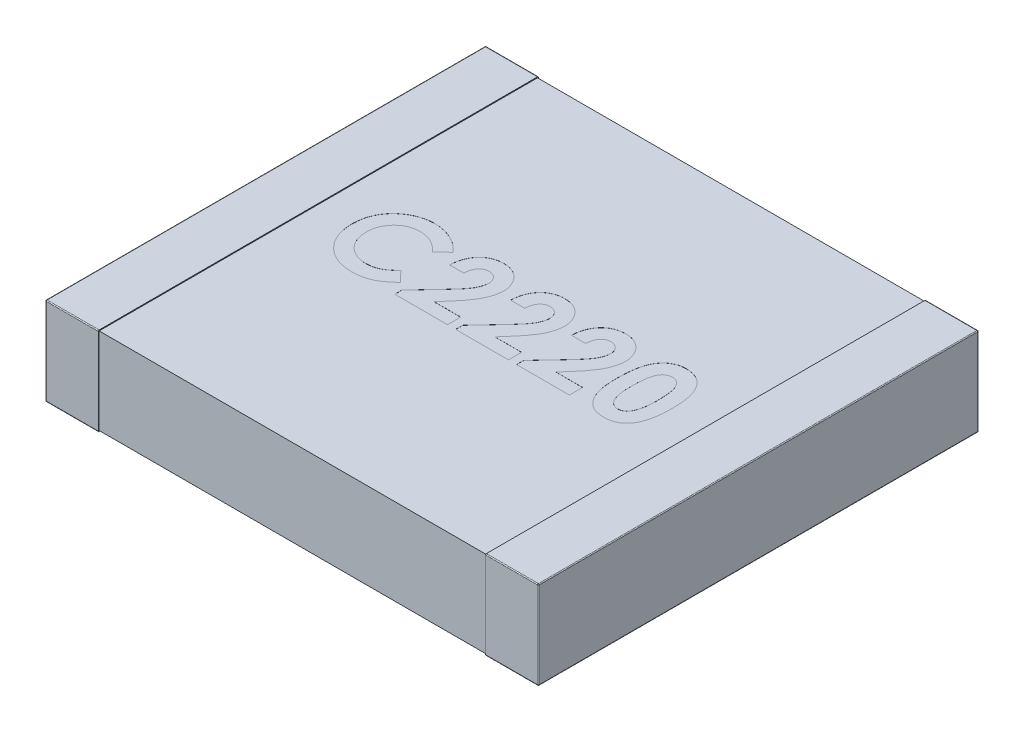
from build123d import *

# Parameters (mm, degrees)
SKETCH1_W            = 0.6
SKETCH1_H            = 5
THICKNESS_DEPTH      = 1
FILLET1_R            = 0.01
SKETCH2_W            = 4.98
SKETCH2_H            = 0.98
BOSS_EXTRUDE2_DEPTH  = 2.2
FILLET1_OF_MIRROR3_R = 0.01
CUT_EXTRUDE1_DEPTH   = 0.001


with BuildPart() as part:
    # Sketch1 → THICKNESS (new body)
    with BuildSketch(Plane(origin=(0, 0, 0), x_dir=(1, 0, 0), z_dir=(0, 1, 0))):
        with Locations((-2.5, 0)):
            Rectangle(SKETCH1_W, SKETCH1_H)
    thickness = extrude(amount=THICKNESS_DEPTH)

    # Fillet1
    fillet1_edges = [part.edges().sort_by_distance(p)[0] for p in [
        (-2.5, 1, -2.5),
        (-2.8, 1, 0),
        (-2.5, 0, -2.5),
        (-2.5, 0, 2.5),
        (-2.8, 0, 0),
        (-2.5, 1, 2.5),
        (-2.8, 0.5, -2.5),
        (-2.8, 0.5, 2.5),
    ]]
    fillet(fillet1_edges, radius=FILLET1_R)

    # Sketch2 → Boss-Extrude2 (add)
    with BuildSketch(Plane(origin=(0, 0, 0), x_dir=(0, 0, -1), z_dir=(1, 0, 0))):
        with Locations((0, 0.5)):
            Rectangle(SKETCH2_W, SKETCH2_H)
    boss_extrude2 = extrude(amount=-BOSS_EXTRUDE2_DEPTH)

    # Mirror3: THICKNESS, Boss-Extrude2 across plane
    add(thickness.mirror(Plane(origin=(0, 0, 0), x_dir=(0, 0, 1), z_dir=(1, 0, 0))))
    add(boss_extrude2.mirror(Plane(origin=(0, 0, 0), x_dir=(0, 0, 1), z_dir=(1, 0, 0))))

    # Fillet1 of Mirror3
    fillet1_of_mirror3_edges = [part.edges().sort_by_distance(p)[0] for p in [
        (2.5, 1, -2.5),
        (2.8, 1, 0),
        (2.5, 0, -2.5),
        (2.5, 0, 2.5),
        (2.8, 0, 0),
        (2.5, 1, 2.5),
        (2.8, 0.5, -2.5),
        (2.8, 0.5, 2.5),
    ]]
    fillet(fillet1_of_mirror3_edges, radius=FILLET1_OF_MIRROR3_R)

    # Sketch3 → Cut-Extrude1 (cut)
    with BuildSketch(Plane(origin=(0, 0.99, 0), x_dir=(1, 0, 0), z_dir=(0, 1, 0))):
        with BuildLine():
            Line((-0.963461538, 0.293870192), (-1.081911058, 0.180649038))
            add(Edge.make_bspline(
                [(-1.081911058, 0.180649038), (-1.091958911, 0.191038536), (-1.111585516, 0.211332478), (-1.143211363, 0.23819987), (-1.176101092, 0.260590206), (-1.2096149, 0.279447204), (-1.244355602, 0.293713867), (-1.279921502, 0.304110224), (-1.316539698, 0.310448491), (-1.341321485, 0.3111737), (-1.353786058, 0.311538462)],
                knots=[0, 0, 0, 0, 4.3344e-05, 8.4665e-05, 0.000124221, 0.000162552, 0.000199817, 0.000236617, 0.000273548, 0.00031092, 0.00031092, 0.00031092, 0.00031092], degree=3))
            add(Edge.make_bspline(
                [(-1.353786058, 0.311538462), (-1.364195491, 0.311250288), (-1.384737361, 0.310681608), (-1.414898208, 0.306512625), (-1.443748618, 0.299423089), (-1.471387348, 0.289652395), (-1.497733072, 0.277009635), (-1.522841027, 0.261504594), (-1.546649309, 0.243277306), (-1.568843425, 0.222422079), (-1.589145823, 0.199636176), (-1.607084284, 0.175323672), (-1.622110622, 0.149540266), (-1.634442494, 0.122547072), (-1.644048545, 0.094219153), (-1.650908473, 0.064575581), (-1.654876071, 0.033581052), (-1.655468262, 0.012511202), (-1.655769231, 0.001802885)],
                knots=[0, 0, 0, 0, 3.1223e-05, 6.1616e-05, 9.1131e-05, 0.000120213, 0.000149404, 0.000178625, 0.00020859, 0.000239203, 0.000269851, 0.000300033, 0.000329687, 0.000359215, 0.000388919, 0.000419269, 0.000450353, 0.000482477, 0.000482477, 0.000482477, 0.000482477], degree=3))
            add(Edge.make_bspline(
                [(-1.655769231, 0.001802885), (-1.655682495, -0.005712962), (-1.655511537, -0.02052685), (-1.6536401, -0.042440701), (-1.650626645, -0.063702318), (-1.646265428, -0.084279494), (-1.640811685, -0.104190062), (-1.634413201, -0.123605789), (-1.626386398, -0.142258394), (-1.617476526, -0.160364514), (-1.607114447, -0.177430102), (-1.595942214, -0.193703557), (-1.583827751, -0.209105106), (-1.570692593, -0.22357179), (-1.556351878, -0.236877525), (-1.541176261, -0.249422432), (-1.52490975, -0.260892467), (-1.507890241, -0.271575486), (-1.489970709, -0.280855915), (-1.47163735, -0.289262191), (-1.452612195, -0.296089337), (-1.433126886, -0.30159264), (-1.413251056, -0.306272376), (-1.392790303, -0.309153834), (-1.371921994, -0.311335928), (-1.35781852, -0.31147066), (-1.350721154, -0.311538462)],
                knots=[0, 0, 0, 0, 2.2543e-05, 4.4432e-05, 6.5926e-05, 8.6929e-05, 0.000107485, 0.000127838, 0.000148197, 0.000168354, 0.000188328, 0.000208032, 0.000227544, 0.00024707, 0.000266585, 0.000286184, 0.000306094, 0.000326255, 0.000346416, 0.000366589, 0.000386721, 0.000406979, 0.000427316, 0.000447918, 0.000468925, 0.000490206, 0.000490206, 0.000490206, 0.000490206], degree=3))
            add(Edge.make_bspline(
                [(-1.350721154, -0.311538462), (-1.338682801, -0.311190248), (-1.315030568, -0.3105061), (-1.280317515, -0.305156159), (-1.247239434, -0.296355809), (-1.220810205, -0.285963106), (-1.200103603, -0.275700177), (-1.184339972, -0.266207473), (-1.16803915, -0.255588842), (-1.151471878, -0.243443524), (-1.134451808, -0.229917269), (-1.117279384, -0.214713826), (-1.099514987, -0.198333822), (-1.087877707, -0.186643092), (-1.081911058, -0.180649038)],
                knots=[0, 0, 0, 0, 3.6103e-05, 7.0932e-05, 0.000105088, 0.0001386, 0.000155935, 0.000174363, 0.000193765, 0.000214284, 0.000235964, 0.000258962, 0.000283073, 0.000308443, 0.000308443, 0.000308443, 0.000308443], degree=3))
            Line((-1.081911058, -0.180649038), (-0.967067308, -0.301262019))
            add(Edge.make_bspline(
                [(-0.967067308, -0.301262019), (-0.975140205, -0.309056148), (-0.990896775, -0.324268621), (-1.014665122, -0.345868914), (-1.038403556, -0.365279177), (-1.061538606, -0.38320392), (-1.084449247, -0.399120951), (-1.107133051, -0.413046166), (-1.129333226, -0.425331754), (-1.151510766, -0.435770525), (-1.173803671, -0.444634125), (-1.196740451, -0.452265103), (-1.220391226, -0.458720636), (-1.244900443, -0.463929404), (-1.270039495, -0.468106132), (-1.296043651, -0.470925399), (-1.322748032, -0.472820699), (-1.340862027, -0.472991008), (-1.35, -0.473076923)],
                knots=[0, 0, 0, 0, 3.3664e-05, 6.5705e-05, 9.6315e-05, 0.000125631, 0.000153488, 0.000179956, 0.000205453, 0.000229567, 0.000253437, 0.000277383, 0.00030205, 0.000326944, 0.000352523, 0.000378465, 0.000405388, 0.000432797, 0.000432797, 0.000432797, 0.000432797], degree=3))
            add(Edge.make_bspline(
                [(-1.35, -0.473076923), (-1.366785325, -0.472649032), (-1.39962954, -0.471811767), (-1.447761881, -0.465608204), (-1.493486313, -0.455208039), (-1.536914075, -0.440499337), (-1.578031358, -0.42170966), (-1.616827643, -0.398674399), (-1.653240398, -0.371454753), (-1.686975481, -0.340369765), (-1.717490469, -0.306039005), (-1.744462185, -0.269177187), (-1.766773189, -0.229603149), (-1.785298496, -0.187901525), (-1.799785043, -0.143882016), (-1.809981116, -0.097497005), (-1.81626896, -0.048791279), (-1.816956859, -0.015524146), (-1.817307692, 0.001442308)],
                knots=[0, 0, 0, 0, 5.0347e-05, 9.8515e-05, 0.000145311, 0.000190808, 0.000235824, 0.000280688, 0.000325905, 0.000371966, 0.000418065, 0.000463503, 0.000508719, 0.000554081, 0.000600204, 0.000647488, 0.000696371, 0.000747251, 0.000747251, 0.000747251, 0.000747251], degree=3))
            add(Edge.make_bspline(
                [(-1.817307692, 0.001442308), (-1.817159447, 0.012507684), (-1.816865662, 0.034436556), (-1.81377795, 0.06673956), (-1.809473501, 0.098229211), (-1.802644883, 0.128578542), (-1.794413658, 0.158196414), (-1.784177048, 0.186760916), (-1.771951402, 0.214354145), (-1.758130783, 0.241022293), (-1.742495654, 0.266590656), (-1.725029498, 0.290839561), (-1.706181964, 0.313956205), (-1.685500174, 0.335633904), (-1.663284662, 0.35606299), (-1.639435128, 0.375132756), (-1.614095016, 0.393116684), (-1.587195738, 0.40955101), (-1.559259876, 0.424416732), (-1.530639775, 0.437528934), (-1.50140575, 0.448487715), (-1.471681407, 0.45757762), (-1.44134116, 0.464362591), (-1.41060157, 0.469498595), (-1.37920108, 0.472369654), (-1.358118371, 0.472839665), (-1.347475962, 0.473076923)],
                knots=[0, 0, 0, 0, 3.3185e-05, 6.5765e-05, 9.7279e-05, 0.00012847, 0.000159004, 0.000189457, 0.000219405, 0.000249482, 0.000279506, 0.000309225, 0.000339073, 0.000368914, 0.000399027, 0.000429548, 0.000460462, 0.000492186, 0.000524045, 0.000555348, 0.000586557, 0.00061764, 0.000648518, 0.000679758, 0.000711081, 0.00074301, 0.00074301, 0.00074301, 0.00074301], degree=3))
            add(Edge.make_bspline(
                [(-1.347475962, 0.473076923), (-1.338396895, 0.472940921), (-1.320333158, 0.47267033), (-1.293433223, 0.470414663), (-1.266748421, 0.466872159), (-1.240374292, 0.461527277), (-1.21412218, 0.455182225), (-1.18833707, 0.446874256), (-1.162612185, 0.437613459), (-1.137350983, 0.426544066), (-1.112518204, 0.414460824), (-1.088695593, 0.400751948), (-1.065483171, 0.386261065), (-1.043395312, 0.370130543), (-1.022018263, 0.352945465), (-1.001463806, 0.334625653), (-0.981912319, 0.314865662), (-0.969642891, 0.300904063), (-0.963461538, 0.293870192)],
                knots=[0, 0, 0, 0, 2.7233e-05, 5.4183e-05, 8.093e-05, 0.000107943, 0.000134878, 0.000161906, 0.000189169, 0.000216867, 0.000244603, 0.000271975, 0.000299284, 0.000326656, 0.000353968, 0.000381546, 0.000409211, 0.000437299, 0.000437299, 0.000437299, 0.000437299], degree=3))
        make_face()
        with BuildLine():
            Line((-0.698076923, 0.15), (-0.859615385, 0.15))
            add(Edge.make_bspline(
                [(-0.859615385, 0.15), (-0.858917725, 0.16221953), (-0.857554539, 0.186095758), (-0.852132132, 0.220776744), (-0.844866293, 0.253546461), (-0.835169065, 0.284290279), (-0.822983865, 0.312997026), (-0.808624247, 0.339764564), (-0.791723358, 0.364451962), (-0.772640902, 0.386940164), (-0.751700849, 0.407114537), (-0.729337933, 0.425002403), (-0.705210084, 0.439763021), (-0.679758138, 0.451909642), (-0.652986428, 0.461614228), (-0.624641652, 0.46810253), (-0.594969234, 0.472496471), (-0.574656062, 0.472880958), (-0.564302885, 0.473076923)],
                knots=[0, 0, 0, 0, 3.6698e-05, 7.1706e-05, 0.000105165, 0.000137323, 0.000168264, 0.000198596, 0.0002283, 0.000257848, 0.000286918, 0.000315413, 0.000343582, 0.000371564, 0.000399906, 0.000428812, 0.000458668, 0.000489703, 0.000489703, 0.000489703, 0.000489703], degree=3))
            add(Edge.make_bspline(
                [(-0.564302885, 0.473076923), (-0.551594507, 0.472680388), (-0.526784775, 0.471906259), (-0.490734267, 0.465302682), (-0.457067034, 0.454257178), (-0.425807549, 0.438823696), (-0.39722193, 0.419217074), (-0.371314916, 0.395839388), (-0.348869978, 0.368200159), (-0.329744807, 0.337449412), (-0.313854077, 0.304888698), (-0.302718514, 0.27121957), (-0.295399229, 0.237335469), (-0.294618582, 0.214519631), (-0.294230769, 0.203185096)],
                knots=[0, 0, 0, 0, 3.8102e-05, 7.4385e-05, 0.000109504, 0.000144094, 0.000178598, 0.000213186, 0.000248412, 0.000285028, 0.000321638, 0.000356814, 0.000391217, 0.00042518, 0.00042518, 0.00042518, 0.00042518], degree=3))
            add(Edge.make_bspline(
                [(-0.294230769, 0.203185096), (-0.294381763, 0.196329168), (-0.294685676, 0.182529879), (-0.296798825, 0.161648167), (-0.299968966, 0.140377702), (-0.304748765, 0.118736722), (-0.310709567, 0.09671916), (-0.317940882, 0.074259124), (-0.326610446, 0.051483956), (-0.336573583, 0.028137325), (-0.34845963, 0.004143433), (-0.36229928, -0.020857397), (-0.378459868, -0.046842989), (-0.396746195, -0.073960064), (-0.417247073, -0.102165855), (-0.44006258, -0.131375398), (-0.464929936, -0.161691618), (-0.482578998, -0.181956309), (-0.491646635, -0.192367788)],
                knots=[0, 0, 0, 0, 2.0566e-05, 4.1393e-05, 6.2913e-05, 8.505e-05, 0.000107836, 0.000131326, 0.000155803, 0.00018092, 0.000207447, 0.000236096, 0.000266616, 0.000299218, 0.000334198, 0.000371199, 0.000410396, 0.000451813, 0.000451813, 0.000451813, 0.000451813], degree=3))
            Line((-0.491646635, -0.192367788), (-0.585576923, -0.3))
            Line((-0.585576923, -0.3), (-0.282692308, -0.3))
            Line((-0.282692308, -0.3), (-0.282692308, -0.45))
            Line((-0.282692308, -0.45), (-0.882692308, -0.45))
            Line((-0.882692308, -0.45), (-0.882692308, -0.368149038))
            Line((-0.882692308, -0.368149038), (-0.616225962, -0.084555288))
            add(Edge.make_bspline(
                [(-0.616225962, -0.084555288), (-0.608511076, -0.076282771), (-0.593569631, -0.060261357), (-0.572309494, -0.036732207), (-0.553070948, -0.014403605), (-0.53625292, 0.006962204), (-0.520972822, 0.026672198), (-0.507911991, 0.045320463), (-0.496950932, 0.062738412), (-0.485051148, 0.083741415), (-0.473750264, 0.108791234), (-0.46338102, 0.137649653), (-0.457060248, 0.165231655), (-0.456187781, 0.18320468), (-0.455769231, 0.191826923)],
                knots=[0, 0, 0, 0, 3.3934e-05, 6.5721e-05, 9.5132e-05, 0.000122331, 0.000147284, 0.000169941, 0.000190599, 0.000209004, 0.000242322, 0.000272884, 0.000300926, 0.000326784, 0.000326784, 0.000326784, 0.000326784], degree=3))
            add(Edge.make_bspline(
                [(-0.455769231, 0.191826923), (-0.456082171, 0.200168278), (-0.456688542, 0.21633099), (-0.463352074, 0.239322362), (-0.473675448, 0.260138702), (-0.48822254, 0.278157994), (-0.505843624, 0.292965642), (-0.526206442, 0.303979155), (-0.549144978, 0.310333901), (-0.565225328, 0.311129288), (-0.573497596, 0.311538462)],
                knots=[0, 0, 0, 0, 2.4959e-05, 4.8362e-05, 7.1179e-05, 9.4267e-05, 0.000117305, 0.000139809, 0.000163212, 0.000188006, 0.000188006, 0.000188006, 0.000188006], degree=3))
            add(Edge.make_bspline(
                [(-0.573497596, 0.311538462), (-0.577771155, 0.311387308), (-0.586184343, 0.311089738), (-0.598551071, 0.309108893), (-0.610318902, 0.305617861), (-0.621618817, 0.300940369), (-0.632330221, 0.294740321), (-0.642426096, 0.287097773), (-0.652012816, 0.27820694), (-0.661046411, 0.268095624), (-0.669268162, 0.256811392), (-0.676570692, 0.244457302), (-0.682608668, 0.231041024), (-0.687924721, 0.216739672), (-0.692024716, 0.201399639), (-0.695010021, 0.185112732), (-0.697279549, 0.167905449), (-0.697806297, 0.15607706), (-0.698076923, 0.15)],
                knots=[0, 0, 0, 0, 1.2821e-05, 2.524e-05, 3.7449e-05, 4.957e-05, 6.1847e-05, 7.4467e-05, 8.748e-05, 0.000101015, 0.000115079, 0.000129302, 0.000143984, 0.000159156, 0.000175032, 0.000191545, 0.000208808, 0.00022705, 0.00022705, 0.00022705, 0.00022705], degree=3))
        make_face()
        with BuildLine():
            Line((-0.005769231, 0.15), (-0.167307692, 0.15))
            add(Edge.make_bspline(
                [(-0.167307692, 0.15), (-0.166610032, 0.16221953), (-0.165246847, 0.186095758), (-0.15982444, 0.220776744), (-0.1525586, 0.253546461), (-0.142861373, 0.284290279), (-0.130676172, 0.312997026), (-0.116316555, 0.339764564), (-0.099415665, 0.364451962), (-0.08033321, 0.386940164), (-0.059393156, 0.407114537), (-0.03703024, 0.425002403), (-0.012902392, 0.439763021), (0.012549555, 0.451909642), (0.039321265, 0.461614228), (0.067666041, 0.46810253), (0.097338458, 0.472496471), (0.117651631, 0.472880958), (0.128004808, 0.473076923)],
                knots=[0, 0, 0, 0, 3.6698e-05, 7.1706e-05, 0.000105165, 0.000137323, 0.000168264, 0.000198596, 0.0002283, 0.000257848, 0.000286918, 0.000315413, 0.000343582, 0.000371564, 0.000399906, 0.000428812, 0.000458668, 0.000489703, 0.000489703, 0.000489703, 0.000489703], degree=3))
            add(Edge.make_bspline(
                [(0.128004808, 0.473076923), (0.140713186, 0.472680388), (0.165522917, 0.471906259), (0.201573426, 0.465302682), (0.235240659, 0.454257178), (0.266500143, 0.438823696), (0.295085763, 0.419217074), (0.320992776, 0.395839388), (0.343437714, 0.368200159), (0.362562885, 0.337449412), (0.378453616, 0.304888698), (0.389589178, 0.27121957), (0.396908463, 0.237335469), (0.39768911, 0.214519631), (0.398076923, 0.203185096)],
                knots=[0, 0, 0, 0, 3.8102e-05, 7.4385e-05, 0.000109504, 0.000144094, 0.000178598, 0.000213186, 0.000248412, 0.000285028, 0.000321638, 0.000356814, 0.000391217, 0.00042518, 0.00042518, 0.00042518, 0.00042518], degree=3))
            add(Edge.make_bspline(
                [(0.398076923, 0.203185096), (0.397925929, 0.196329168), (0.397622016, 0.182529879), (0.395508867, 0.161648167), (0.392338727, 0.140377702), (0.387558927, 0.118736722), (0.381598125, 0.09671916), (0.374366811, 0.074259124), (0.365697246, 0.051483956), (0.35573411, 0.028137325), (0.343848063, 0.004143433), (0.330008413, -0.020857397), (0.313847824, -0.046842989), (0.295561498, -0.073960064), (0.27506062, -0.102165855), (0.252245112, -0.131375398), (0.227377756, -0.161691618), (0.209728694, -0.181956309), (0.200661058, -0.192367788)],
                knots=[0, 0, 0, 0, 2.0566e-05, 4.1393e-05, 6.2913e-05, 8.505e-05, 0.000107836, 0.000131326, 0.000155803, 0.00018092, 0.000207447, 0.000236096, 0.000266616, 0.000299218, 0.000334198, 0.000371199, 0.000410396, 0.000451813, 0.000451813, 0.000451813, 0.000451813], degree=3))
            Line((0.200661058, -0.192367788), (0.106730769, -0.3))
            Line((0.106730769, -0.3), (0.409615385, -0.3))
            Line((0.409615385, -0.3), (0.409615385, -0.45))
            Line((0.409615385, -0.45), (-0.190384615, -0.45))
            Line((-0.190384615, -0.45), (-0.190384615, -0.368149038))
            Line((-0.190384615, -0.368149038), (0.076081731, -0.084555288))
            add(Edge.make_bspline(
                [(0.076081731, -0.084555288), (0.083796616, -0.076282771), (0.098738062, -0.060261357), (0.119998198, -0.036732207), (0.139236744, -0.014403605), (0.156054772, 0.006962204), (0.171334871, 0.026672198), (0.184395701, 0.045320463), (0.19535676, 0.062738412), (0.207256545, 0.083741415), (0.218557428, 0.108791234), (0.228926673, 0.137649653), (0.235247445, 0.165231655), (0.236119911, 0.18320468), (0.236538462, 0.191826923)],
                knots=[0, 0, 0, 0, 3.3934e-05, 6.5721e-05, 9.5132e-05, 0.000122331, 0.000147284, 0.000169941, 0.000190599, 0.000209004, 0.000242322, 0.000272884, 0.000300926, 0.000326784, 0.000326784, 0.000326784, 0.000326784], degree=3))
            add(Edge.make_bspline(
                [(0.236538462, 0.191826923), (0.236225521, 0.200168278), (0.23561915, 0.21633099), (0.228955619, 0.239322362), (0.218632245, 0.260138702), (0.204085153, 0.278157994), (0.186464068, 0.292965642), (0.16610125, 0.303979155), (0.143162715, 0.310333901), (0.127082365, 0.311129288), (0.118810096, 0.311538462)],
                knots=[0, 0, 0, 0, 2.4959e-05, 4.8362e-05, 7.1179e-05, 9.4267e-05, 0.000117305, 0.000139809, 0.000163212, 0.000188006, 0.000188006, 0.000188006, 0.000188006], degree=3))
            add(Edge.make_bspline(
                [(0.118810096, 0.311538462), (0.114536537, 0.311387308), (0.106123349, 0.311089738), (0.093756621, 0.309108893), (0.081988791, 0.305617861), (0.070688876, 0.300940369), (0.059977472, 0.294740321), (0.049881596, 0.287097773), (0.040294876, 0.27820694), (0.031261281, 0.268095624), (0.02303953, 0.256811392), (0.015737001, 0.244457302), (0.009699025, 0.231041024), (0.004382971, 0.216739672), (0.000282976, 0.201399639), (-0.002702329, 0.185112732), (-0.004971857, 0.167905449), (-0.005498604, 0.15607706), (-0.005769231, 0.15)],
                knots=[0, 0, 0, 0, 1.2821e-05, 2.524e-05, 3.7449e-05, 4.957e-05, 6.1847e-05, 7.4467e-05, 8.748e-05, 0.000101015, 0.000115079, 0.000129302, 0.000143984, 0.000159156, 0.000175032, 0.000191545, 0.000208808, 0.00022705, 0.00022705, 0.00022705, 0.00022705], degree=3))
        make_face()
        with BuildLine():
            Line((0.686538462, 0.15), (0.525, 0.15))
            add(Edge.make_bspline(
                [(0.525, 0.15), (0.52569766, 0.16221953), (0.527060845, 0.186095758), (0.532483252, 0.220776744), (0.539749092, 0.253546461), (0.549446319, 0.284290279), (0.56163152, 0.312997026), (0.575991137, 0.339764564), (0.592892027, 0.364451962), (0.611974482, 0.386940164), (0.632914536, 0.407114537), (0.655277452, 0.425002403), (0.679405301, 0.439763021), (0.704857247, 0.451909642), (0.731628957, 0.461614228), (0.759973733, 0.46810253), (0.78964615, 0.472496471), (0.809959323, 0.472880958), (0.8203125, 0.473076923)],
                knots=[0, 0, 0, 0, 3.6698e-05, 7.1706e-05, 0.000105165, 0.000137323, 0.000168264, 0.000198596, 0.0002283, 0.000257848, 0.000286918, 0.000315413, 0.000343582, 0.000371564, 0.000399906, 0.000428812, 0.000458668, 0.000489703, 0.000489703, 0.000489703, 0.000489703], degree=3))
            add(Edge.make_bspline(
                [(0.8203125, 0.473076923), (0.833020878, 0.472680388), (0.85783061, 0.471906259), (0.893881118, 0.465302682), (0.927548351, 0.454257178), (0.958807836, 0.438823696), (0.987393455, 0.419217074), (1.013300469, 0.395839388), (1.035745407, 0.368200159), (1.054870577, 0.337449412), (1.070761308, 0.304888698), (1.08189687, 0.27121957), (1.089216156, 0.237335469), (1.089996803, 0.214519631), (1.090384615, 0.203185096)],
                knots=[0, 0, 0, 0, 3.8102e-05, 7.4385e-05, 0.000109504, 0.000144094, 0.000178598, 0.000213186, 0.000248412, 0.000285028, 0.000321638, 0.000356814, 0.000391217, 0.00042518, 0.00042518, 0.00042518, 0.00042518], degree=3))
            add(Edge.make_bspline(
                [(1.090384615, 0.203185096), (1.090233622, 0.196329168), (1.089929708, 0.182529879), (1.08781656, 0.161648167), (1.084646419, 0.140377702), (1.079866619, 0.118736722), (1.073905817, 0.09671916), (1.066674503, 0.074259124), (1.058004939, 0.051483956), (1.048041802, 0.028137325), (1.036155755, 0.004143433), (1.022316105, -0.020857397), (1.006155517, -0.046842989), (0.98786919, -0.073960064), (0.967368312, -0.102165855), (0.944552804, -0.131375398), (0.919685448, -0.161691618), (0.902036386, -0.181956309), (0.89296875, -0.192367788)],
                knots=[0, 0, 0, 0, 2.0566e-05, 4.1393e-05, 6.2913e-05, 8.505e-05, 0.000107836, 0.000131326, 0.000155803, 0.00018092, 0.000207447, 0.000236096, 0.000266616, 0.000299218, 0.000334198, 0.000371199, 0.000410396, 0.000451813, 0.000451813, 0.000451813, 0.000451813], degree=3))
            Line((0.89296875, -0.192367788), (0.799038462, -0.3))
            Line((0.799038462, -0.3), (1.101923077, -0.3))
            Line((1.101923077, -0.3), (1.101923077, -0.45))
            Line((1.101923077, -0.45), (0.501923077, -0.45))
            Line((0.501923077, -0.45), (0.501923077, -0.368149038))
            Line((0.501923077, -0.368149038), (0.768389423, -0.084555288))
            add(Edge.make_bspline(
                [(0.768389423, -0.084555288), (0.776104309, -0.076282771), (0.791045754, -0.060261357), (0.812305891, -0.036732207), (0.831544437, -0.014403605), (0.848362464, 0.006962204), (0.863642563, 0.026672198), (0.876703394, 0.045320463), (0.887664453, 0.062738412), (0.899564237, 0.083741415), (0.91086512, 0.108791234), (0.921234365, 0.137649653), (0.927555137, 0.165231655), (0.928427603, 0.18320468), (0.928846154, 0.191826923)],
                knots=[0, 0, 0, 0, 3.3934e-05, 6.5721e-05, 9.5132e-05, 0.000122331, 0.000147284, 0.000169941, 0.000190599, 0.000209004, 0.000242322, 0.000272884, 0.000300926, 0.000326784, 0.000326784, 0.000326784, 0.000326784], degree=3))
            add(Edge.make_bspline(
                [(0.928846154, 0.191826923), (0.928533214, 0.200168278), (0.927926842, 0.21633099), (0.921263311, 0.239322362), (0.910939937, 0.260138702), (0.896392845, 0.278157994), (0.878771761, 0.292965642), (0.858408942, 0.303979155), (0.835470407, 0.310333901), (0.819390057, 0.311129288), (0.811117788, 0.311538462)],
                knots=[0, 0, 0, 0, 2.4959e-05, 4.8362e-05, 7.1179e-05, 9.4267e-05, 0.000117305, 0.000139809, 0.000163212, 0.000188006, 0.000188006, 0.000188006, 0.000188006], degree=3))
            add(Edge.make_bspline(
                [(0.811117788, 0.311538462), (0.806844229, 0.311387308), (0.798431042, 0.311089738), (0.786064313, 0.309108893), (0.774296483, 0.305617861), (0.762996568, 0.300940369), (0.752285164, 0.294740321), (0.742189288, 0.287097773), (0.732602569, 0.27820694), (0.723568973, 0.268095624), (0.715347222, 0.256811392), (0.708044693, 0.244457302), (0.702006717, 0.231041024), (0.696690663, 0.216739672), (0.692590668, 0.201399639), (0.689605363, 0.185112732), (0.687335836, 0.167905449), (0.686809088, 0.15607706), (0.686538462, 0.15)],
                knots=[0, 0, 0, 0, 1.2821e-05, 2.524e-05, 3.7449e-05, 4.957e-05, 6.1847e-05, 7.4467e-05, 8.748e-05, 0.000101015, 0.000115079, 0.000129302, 0.000143984, 0.000159156, 0.000175032, 0.000191545, 0.000208808, 0.00022705, 0.00022705, 0.00022705, 0.00022705], degree=3))
        make_face()
        with BuildLine():
            add(Edge.make_bspline(
                [(1.508834135, 0.473076923), (1.516653267, 0.472960846), (1.532027769, 0.472732607), (1.554671518, 0.470260595), (1.576483708, 0.466526073), (1.597549672, 0.461317718), (1.617717775, 0.454424646), (1.637134805, 0.446173757), (1.655569642, 0.436132274), (1.673257391, 0.424789904), (1.690191237, 0.411948733), (1.705964187, 0.397309135), (1.720864289, 0.381207968), (1.73456901, 0.363401811), (1.747381847, 0.344052629), (1.759260697, 0.323157356), (1.770114626, 0.300613721), (1.78006528, 0.276381045), (1.788963187, 0.250096088), (1.796457882, 0.221457352), (1.802885838, 0.190458296), (1.808311485, 0.15702176), (1.812412398, 0.121103296), (1.815176496, 0.082726769), (1.817073351, 0.041966163), (1.817228159, 0.014004722), (1.817307692, -0.000360577)],
                knots=[0, 0, 0, 0, 2.3449e-05, 4.6106e-05, 6.8247e-05, 8.9804e-05, 0.000111127, 0.000132125, 0.000153018, 0.000174022, 0.000195116, 0.000216679, 0.000238497, 0.000260856, 0.000284008, 0.000308069, 0.000332904, 0.000359019, 0.000386613, 0.000416088, 0.000447769, 0.000481558, 0.000517675, 0.000556184, 0.000596969, 0.000640062, 0.000640062, 0.000640062, 0.000640062], degree=3))
            add(Edge.make_bspline(
                [(1.817307692, -0.000360577), (1.817221738, -0.014905601), (1.817054731, -0.043166323), (1.815255349, -0.084299747), (1.812156728, -0.122954911), (1.808163001, -0.159127815), (1.802692687, -0.192799358), (1.79628619, -0.224056726), (1.788673193, -0.252888589), (1.779482192, -0.279229982), (1.76959177, -0.303505217), (1.758708151, -0.326004896), (1.747021035, -0.346789962), (1.73479849, -0.366173986), (1.72137043, -0.383585536), (1.707390438, -0.399616696), (1.692249799, -0.413656819), (1.676585993, -0.426429469), (1.659825191, -0.437467602), (1.642140243, -0.447121372), (1.623215857, -0.454951725), (1.603396992, -0.461762148), (1.582345833, -0.466651297), (1.560396878, -0.470530676), (1.537302329, -0.472674659), (1.52157863, -0.472940634), (1.513521635, -0.473076923)],
                knots=[0, 0, 0, 0, 4.3633e-05, 8.4778e-05, 0.000123482, 0.000159956, 0.000193923, 0.000225781, 0.000255651, 0.000283303, 0.000309418, 0.000334253, 0.000358226, 0.000380931, 0.000402927, 0.000424128, 0.000444662, 0.000464794, 0.000484695, 0.000504782, 0.000525141, 0.000546065, 0.000567579, 0.000589897, 0.000612896, 0.000637065, 0.000637065, 0.000637065, 0.000637065], degree=3))
            add(Edge.make_bspline(
                [(1.513521635, -0.473076923), (1.505464857, -0.472938006), (1.489681748, -0.472665868), (1.466524749, -0.470546618), (1.444459476, -0.466635582), (1.423241768, -0.461724613), (1.403019297, -0.454966794), (1.383695096, -0.446902162), (1.365417753, -0.437308627), (1.34813666, -0.426244776), (1.331910819, -0.413557585), (1.316488082, -0.399382756), (1.301902564, -0.38375622), (1.288376147, -0.366502946), (1.275687308, -0.34785323), (1.26396837, -0.327594101), (1.253226378, -0.305755056), (1.243125319, -0.282305653), (1.234348777, -0.256741053), (1.226538062, -0.228832969), (1.22013973, -0.198348763), (1.214993763, -0.165298228), (1.210885226, -0.129751384), (1.207828947, -0.091691073), (1.20601957, -0.051099567), (1.205854314, -0.023199003), (1.205769231, -0.008834135)],
                knots=[0, 0, 0, 0, 2.4169e-05, 4.7348e-05, 6.9666e-05, 9.1356e-05, 0.000112621, 0.000133549, 0.000154113, 0.000174467, 0.000195023, 0.000215822, 0.000237253, 0.000259074, 0.000281526, 0.000304873, 0.000329223, 0.000354505, 0.000381417, 0.000410244, 0.000441396, 0.000474801, 0.000510559, 0.000548723, 0.000589328, 0.00063242, 0.00063242, 0.00063242, 0.00063242], degree=3))
            add(Edge.make_bspline(
                [(1.205769231, -0.008834135), (1.205923351, 0.011124719), (1.206220729, 0.049635585), (1.209989317, 0.105272589), (1.215520649, 0.156699362), (1.223644864, 0.203829878), (1.233690345, 0.246838697), (1.246554105, 0.285442497), (1.261198561, 0.32017545), (1.273677519, 0.340751461), (1.2796875, 0.350661058)],
                knots=[0, 0, 0, 0, 5.9866e-05, 0.000115511, 0.000167216, 0.000214966, 0.000258913, 0.000299563, 0.000336943, 0.000371671, 0.000371671, 0.000371671, 0.000371671], degree=3))
            add(Edge.make_bspline(
                [(1.2796875, 0.350661058), (1.28667562, 0.360396242), (1.300338771, 0.379430447), (1.324229174, 0.404418799), (1.3498963, 0.425790062), (1.37786734, 0.443060583), (1.407699918, 0.456680118), (1.439650163, 0.466299443), (1.473600088, 0.471904109), (1.496914068, 0.472680147), (1.508834135, 0.473076923)],
                knots=[0, 0, 0, 0, 3.5914e-05, 7.0218e-05, 0.00010339, 0.000135859, 0.000168535, 0.000201501, 0.000235675, 0.000271427, 0.000271427, 0.000271427, 0.000271427], degree=3))
        make_face()
        with BuildLine():
            add(Edge.make_bspline(
                [(1.512800481, 0.311538462), (1.505731921, 0.311203426), (1.49187379, 0.310546578), (1.471764983, 0.304970867), (1.452803634, 0.29635888), (1.438380242, 0.285995701), (1.427584476, 0.27606135), (1.420041397, 0.267071086), (1.412767286, 0.2570386), (1.406342425, 0.245511176), (1.40027568, 0.232903009), (1.39434664, 0.219156865), (1.389486385, 0.203935109), (1.384711313, 0.18749697), (1.380527904, 0.169387977), (1.377023125, 0.149460109), (1.373891913, 0.127583772), (1.371707855, 0.103744639), (1.369671658, 0.077967649), (1.368212015, 0.050195384), (1.367601775, 0.020435334), (1.367407798, -5.9971e-05), (1.367307692, -0.010637019)],
                knots=[0, 0, 0, 0, 2.1171e-05, 4.1506e-05, 6.2156e-05, 8.3366e-05, 9.4464e-05, 0.000106099, 0.000118506, 0.000131588, 0.000145618, 0.000160485, 0.000176449, 0.000193511, 0.000211835, 0.000232169, 0.000254199, 0.000278112, 0.000303969, 0.000331771, 0.000361527, 0.00039326, 0.00039326, 0.00039326, 0.00039326], degree=3))
            add(Edge.make_bspline(
                [(1.367307692, -0.010637019), (1.367472454, -0.024340097), (1.367788398, -0.050616765), (1.369443164, -0.088403528), (1.372760004, -0.122792525), (1.376885483, -0.154016823), (1.382679887, -0.181873924), (1.389346725, -0.206627382), (1.397579676, -0.227961651), (1.407094437, -0.246185271), (1.417632464, -0.261688068), (1.429071956, -0.274865514), (1.441023439, -0.286276561), (1.453859958, -0.295545614), (1.467550889, -0.302648989), (1.481981937, -0.307758359), (1.497162273, -0.310886017), (1.507557611, -0.311319723), (1.512800481, -0.311538462)],
                knots=[0, 0, 0, 0, 4.1112e-05, 7.8835e-05, 0.000113423, 0.000144733, 0.000173267, 0.000198726, 0.000221559, 0.00024172, 0.000260272, 0.000277657, 0.000293982, 0.000309743, 0.000324983, 0.000340094, 0.000355546, 0.000371268, 0.000371268, 0.000371268, 0.000371268], degree=3))
            add(Edge.make_bspline(
                [(1.512800481, -0.311538462), (1.517863432, -0.311388784), (1.52777606, -0.311095735), (1.542230892, -0.308087622), (1.555900408, -0.303197085), (1.568743336, -0.296279076), (1.580805613, -0.287481769), (1.592028286, -0.276766505), (1.602326716, -0.264026477), (1.608326629, -0.254571493), (1.611418269, -0.249699519)],
                knots=[0, 0, 0, 0, 1.5171e-05, 2.9703e-05, 4.4074e-05, 5.8593e-05, 7.3306e-05, 8.8736e-05, 0.000105011, 0.000122312, 0.000122312, 0.000122312, 0.000122312], degree=3))
            add(Edge.make_bspline(
                [(1.611418269, -0.249699519), (1.615058155, -0.243042123), (1.622690702, -0.229082102), (1.631523097, -0.205525088), (1.638957716, -0.17895667), (1.645356583, -0.149294164), (1.649733018, -0.116420577), (1.653501999, -0.080544365), (1.655319871, -0.041484868), (1.655615558, -0.014424308), (1.655769231, -0.000360577)],
                knots=[0, 0, 0, 0, 2.2739e-05, 4.7682e-05, 7.5245e-05, 0.000105478, 0.000138624, 0.000174682, 0.000213675, 0.000255869, 0.000255869, 0.000255869, 0.000255869], degree=3))
            add(Edge.make_bspline(
                [(1.655769231, -0.000360577), (1.65570987, 0.013825234), (1.655595612, 0.041130498), (1.653499299, 0.080330416), (1.650580024, 0.116133036), (1.646309966, 0.148458424), (1.640815762, 0.177385053), (1.634044133, 0.202911031), (1.626060887, 0.225086666), (1.616593709, 0.243889844), (1.606108221, 0.259869967), (1.594977555, 0.273579672), (1.583154646, 0.285284673), (1.570659267, 0.295029017), (1.557202207, 0.302474426), (1.543040513, 0.307731501), (1.528145154, 0.310911855), (1.51798441, 0.311326774), (1.512800481, 0.311538462)],
                knots=[0, 0, 0, 0, 4.2552e-05, 8.1904e-05, 0.000117733, 0.000150293, 0.000179676, 0.000206004, 0.000229447, 0.000250249, 0.000269001, 0.000286684, 0.00030313, 0.000318816, 0.000334068, 0.000349071, 0.000363993, 0.000379535, 0.000379535, 0.000379535, 0.000379535], degree=3))
        make_face(mode=Mode.SUBTRACT)
    extrude(amount=-CUT_EXTRUDE1_DEPTH, mode=Mode.SUBTRACT)


solid = part.part
